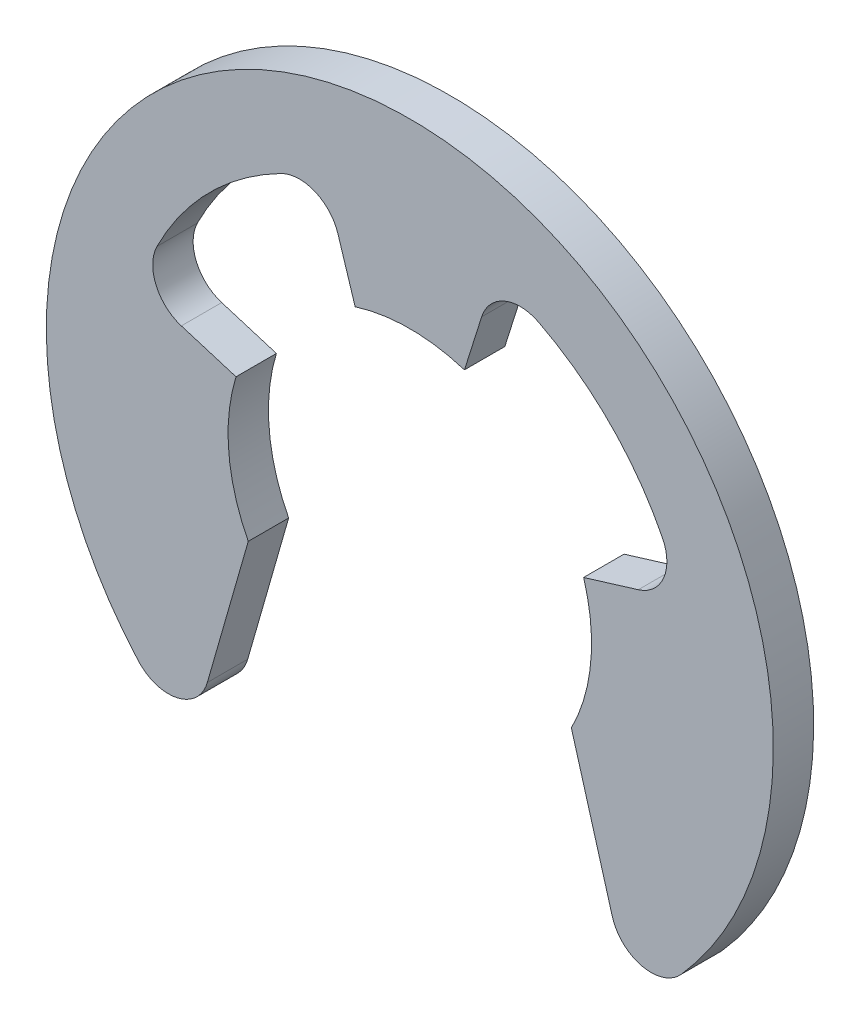
from build123d import *

# Parameters (mm, degrees)
EXTRUDE_1_DEPTH = 1


with BuildPart() as part:
    # 草图1 → 拉伸1 (new body)
    with BuildSketch(Plane.XY):
        with BuildLine():
            Line((4, -2.061552813), (5.013407458, -5.59572462))
            ThreePointArc((5.013407458, -5.59572462), (5.752413022, -6.295075578), (6.721502798, -5.985098172))
            ThreePointArc((6.721502798, -5.985098172), (0, 9), (-6.721502798, -5.985098172))
            ThreePointArc((-6.721502798, -5.985098172), (-5.752413022, -6.295075578), (-5.013407458, -5.59572462))
            Line((-5.013407458, -5.59572462), (-4, -2.061552813))
            ThreePointArc((-4, -2.061552813), (-4.481953497, -0.402607561), (-4.303371402, 1.315672671))
            Line((-4.303371402, 1.315672671), (-5.657575233, 1.729694331))
            ThreePointArc((-5.657575233, 1.729694331), (-6.284318474, 2.2920096), (-6.259404117, 3.133665602))
            ThreePointArc((-6.259404117, 3.133665602), (-4.971297629, 4.928103071), (-3.188169194, 6.231819734))
            ThreePointArc((-3.188169194, 6.231819734), (-2.346762655, 6.264077884), (-1.778999501, 5.642265571))
            Line((-1.778999501, 5.642265571), (-1.353176098, 4.291726278))
            ThreePointArc((-1.353176098, 4.291726278), (0, 4.5), (1.353176098, 4.291726278))
            Line((1.353176098, 4.291726278), (1.778999501, 5.642265571))
            ThreePointArc((1.778999501, 5.642265571), (2.346762655, 6.264077884), (3.188169194, 6.231819734))
            ThreePointArc((3.188169194, 6.231819734), (4.971297629, 4.928103071), (6.259404117, 3.133665602))
            ThreePointArc((6.259404117, 3.133665602), (6.284318474, 2.2920096), (5.657575233, 1.729694331))
            Line((5.657575233, 1.729694331), (4.303371402, 1.315672671))
            ThreePointArc((4.303371402, 1.315672671), (4.481953497, -0.402607561), (4, -2.061552813))
        make_face()
    extrude(amount=EXTRUDE_1_DEPTH)


solid = part.part
